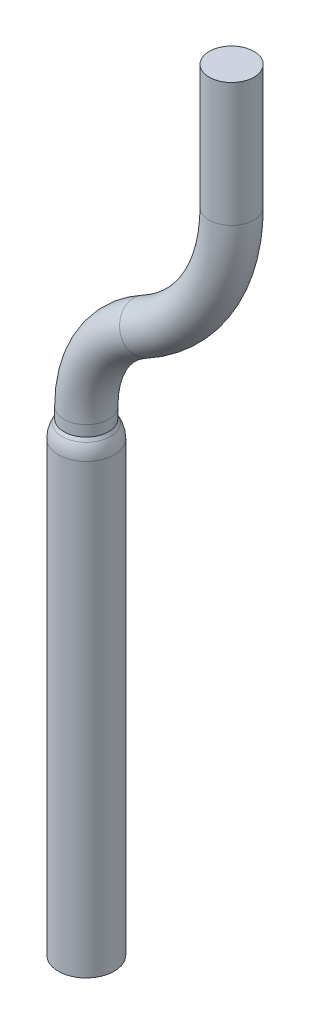
from build123d import *

# Parameters (mm, degrees)
SKETCH2_R = 0.8


with BuildPart() as part:
    # Sweep1: sweep along a path in Sketch1
    with BuildLine(Plane.XY) as sweep1_path:
        Line((-7.5, 30.2), (-7.5, 25.77268488))
        ThreePointArc((-7.5, 25.77268488), (-8.33860484, 22.713273172), (-10.62, 20.509073952))
        ThreePointArc((-10.62, 20.509073952), (-12.140930107, 19.039607805), (-12.7, 17))
        Line((-12.7, 17), (-12.7, 0))
    # Sketch2 → Sweep1 (sweep)
    with BuildSketch(Plane(origin=(0, 0, 0), x_dir=(1, 0, 0), z_dir=(0, 1, 0))):
        with Locations((-12.7, 0)):
            Circle(SKETCH2_R)
    sweep(path=sweep1_path.line)

    # Sketch3 → Revolve1 (revolve)
    with BuildSketch(Plane.XY):
        with BuildLine():
            Line((-12.7, 0), (-11.7, 0))
            Line((-11.7, 0), (-11.7, 16))
            ThreePointArc((-11.7, 16), (-11.734074174, 16.258819045), (-11.833974596, 16.5))
            Line((-11.833974596, 16.5), (-12.7, 18))
            Line((-12.7, 18), (-12.7, 0))
        make_face()
    revolve(axis=Axis((-12.7, 21.819423219, 0), (0, -1, 0)))


solid = part.part
